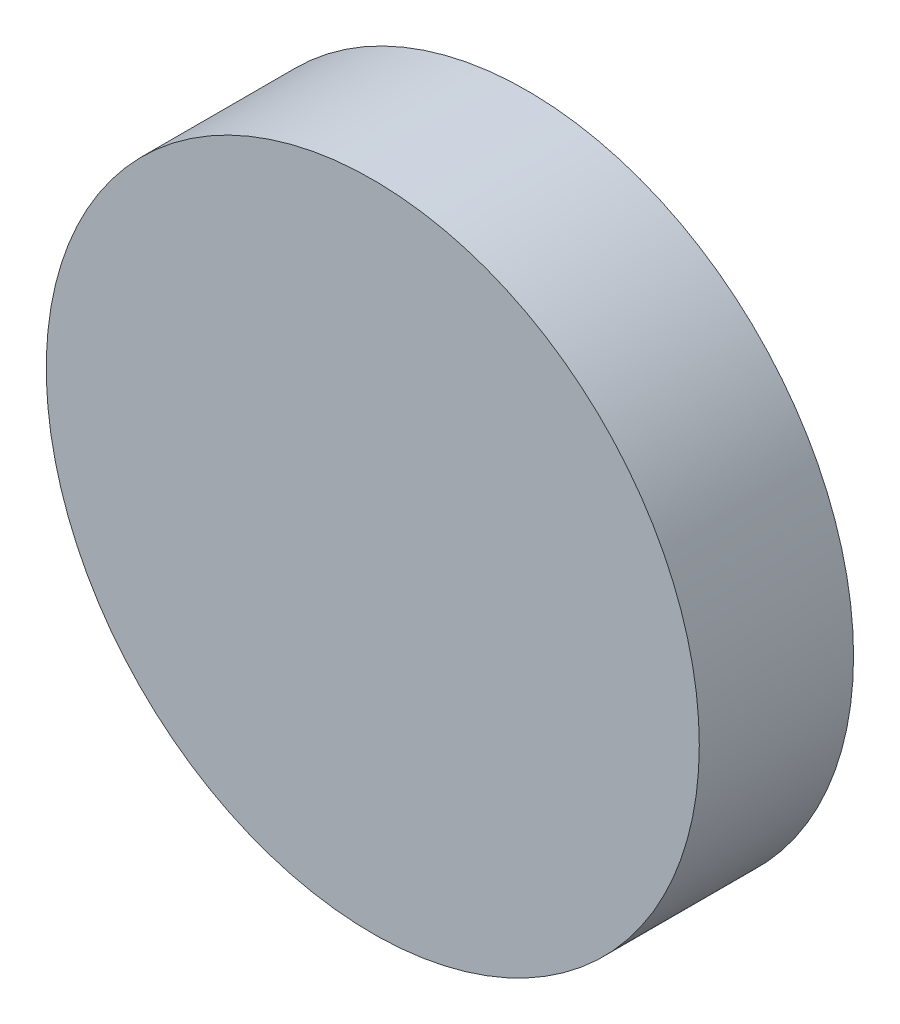
from build123d import *

# Parameters (mm, degrees)
SKETCH_1_R      = 12.7
EXTRUDE_1_DEPTH = 6


with BuildPart() as part:
    # 草图1 → 凸台-拉伸1 (new body)
    with BuildSketch(Plane.XY):
        Circle(SKETCH_1_R)
    extrude(amount=EXTRUDE_1_DEPTH)


solid = part.part
